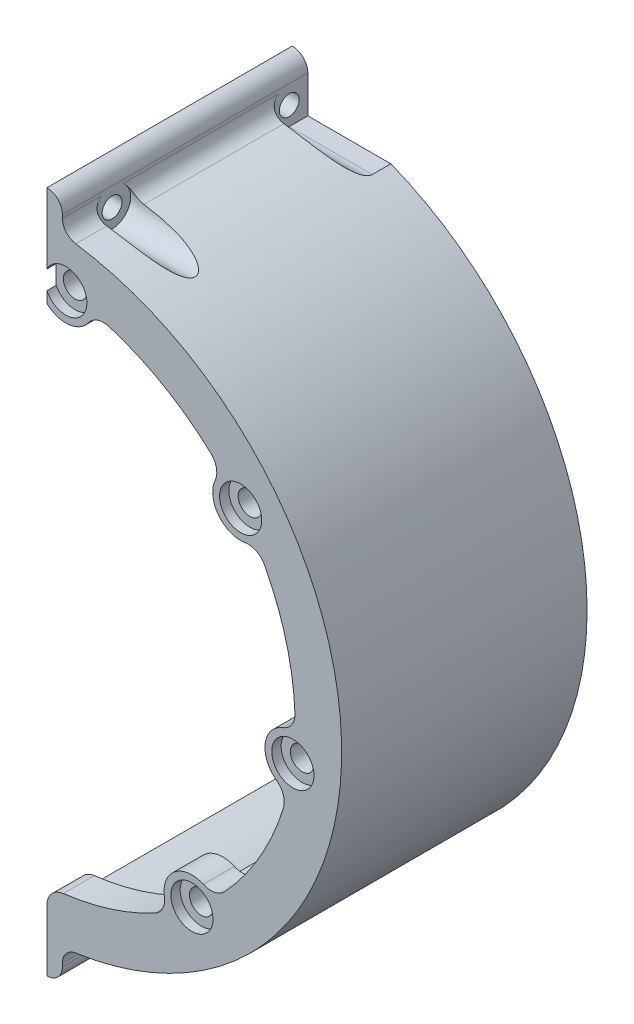
from build123d import *

# Parameters (mm, degrees)
EXTRUDE_1_DEPTH      = 5
EXTRUDE_2_DEPTH      = 34.55
SKETCH_3_W           = 2.5
SKETCH_3_H           = 100
CUT_EXTRUDE_1_DEPTH  = 41
SKETCH_4_R           = 38
CUT_EXTRUDE_2_DEPTH  = 5
EXTRUDE_3_DEPTH      = 39.55
SKETCH_6_R           = 1.9
CUT_EXTRUDE_3_DEPTH  = 10
SKETCH_7_R           = 1.6
CUT_EXTRUDE_4_DEPTH  = 48.5
CUT_EXTRUDE_START    = -2.5
SKETCH_9_R           = 3
CUT_EXTRUDE_7_DEPTH  = 46.0000001
CUT_EXTRUDE_8_DEPTH  = 10
FILLET_1_R           = 3
CUT_EXTRUDE_9_DEPTH  = 34.55
SKETCH_13_R          = 3.4
CUT_EXTRUDE_10_DEPTH = 1.5


with BuildPart() as part:
    # 草图1 → 凸台-拉伸1 (new body)
    with BuildSketch(Plane.XY):
        with BuildLine():
            Line((0, 0), (0, 50))
            ThreePointArc((0, 50), (50, 0), (0, -50))
            Line((0, -50), (0, 0))
        make_face()
    extrude(amount=EXTRUDE_1_DEPTH)

    # 草图2 → 凸台-拉伸2 (add)
    with BuildSketch(Plane(origin=(0, 0, 0), x_dir=(-1, 0, 0), z_dir=(0, 0, -1))):
        with BuildLine():
            Line((0, 46), (0, 50))
            ThreePointArc((0, 50), (-50, 0), (0, -50))
            Line((0, -50), (0, -46))
            ThreePointArc((0, -46), (-46, 0), (0, 46))
        make_face()
    extrude(amount=EXTRUDE_2_DEPTH)

    # 草图3 → 切除-拉伸1 (cut)
    with BuildSketch(Plane.XY.offset(5)):
        with Locations((1.25, 0)):
            Rectangle(SKETCH_3_W, SKETCH_3_H)
    extrude(amount=-CUT_EXTRUDE_1_DEPTH, mode=Mode.SUBTRACT)

    # 草图4 → 切除-拉伸2 (cut)
    with BuildSketch(Plane.XY.offset(5)):
        Circle(SKETCH_4_R)
    extrude(amount=-CUT_EXTRUDE_2_DEPTH, mode=Mode.SUBTRACT)

    # 草图5 → 凸台-拉伸3 (add)
    with BuildSketch(Plane.XY.offset(5)):
        with BuildLine():
            Line((5, -52.5), (5, -51.961524227))
            ThreePointArc((5, -51.961524227), (5.610177635, -50.32489005), (7.142857143, -49.487165931))
            Line((7.142857143, -49.487165931), (2.5, -49.937460889))
            Line((2.5, -49.937460889), (2.5, -55))
            ThreePointArc((2.5, -55), (4.267766953, -54.267766953), (5, -52.5))
        make_face()
        with BuildLine():
            Line((2.5, 55), (2.5, 49.937460889))
            Line((2.5, 49.937460889), (7.142857143, 49.487165931))
            ThreePointArc((7.142857143, 49.487165931), (5.610177635, 50.32489005), (5, 51.961524227))
            Line((5, 51.961524227), (5, 52.5))
            ThreePointArc((5, 52.5), (4.267766953, 54.267766953), (2.5, 55))
        make_face()
    extrude(amount=-EXTRUDE_3_DEPTH)

    # 草图6 → 切除-拉伸3 (cut)
    with BuildSketch(Plane.XY.offset(5)):
        with Locations((33.717516962, 25.872360733)):
            Circle(SKETCH_6_R)
        with Locations((5.547363169, 42.136406608)):
            Circle(SKETCH_6_R)
        with Locations((42.136406608, -5.547363169)):
            Circle(SKETCH_6_R)
        with Locations((25.872360733, -33.717516962)):
            Circle(SKETCH_6_R)
        with Locations((-5.547363169, -42.136406608)):
            Circle(SKETCH_6_R)
        with Locations((-33.717516962, -25.872360733)):
            Circle(SKETCH_6_R)
        with Locations((-42.136406608, 5.547363169)):
            Circle(SKETCH_6_R)
        with Locations((-25.872360733, 33.717516962)):
            Circle(SKETCH_6_R)
    extrude(amount=-CUT_EXTRUDE_3_DEPTH, mode=Mode.SUBTRACT)

    # 草图7 → 切除-拉伸4 (cut, through all)
    with BuildSketch(Plane.ZY.offset(-2.5)):
        with Locations((-3, 49.5)):
            Circle(SKETCH_7_R)
        with Locations((-31.55, 49.5)):
            Circle(SKETCH_7_R)
        with Locations((-31.55, -49.5)):
            Circle(SKETCH_7_R)
        with Locations((-3, -49.5)):
            Circle(SKETCH_7_R)
    extrude(amount=-CUT_EXTRUDE_4_DEPTH, mode=Mode.SUBTRACT)

    # 草图9 → 切除-拉伸7 (cut, through all)
    with BuildSketch(Plane.ZY.offset(-2.5).offset(CUT_EXTRUDE_START)):
        with Locations((-3, 49.5)):
            Circle(SKETCH_9_R)
        with Locations((-3, -49.5)):
            Circle(SKETCH_9_R)
        with BuildLine():
            Line((-31.55, 52.5), (-34.55, 52.5))
            Line((-34.55, 52.5), (-34.55, 46.5))
            Line((-34.55, 46.5), (-31.55, 46.5))
            ThreePointArc((-31.55, 46.5), (-28.55, 49.5), (-31.55, 52.5))
        make_face()
        with BuildLine():
            Line((-31.55, -46.5), (-34.55, -46.5))
            Line((-34.55, -46.5), (-34.55, -52.5))
            Line((-34.55, -52.5), (-31.55, -52.5))
            ThreePointArc((-31.55, -52.5), (-28.55, -49.5), (-31.55, -46.5))
        make_face()
    extrude(amount=-CUT_EXTRUDE_7_DEPTH, mode=Mode.SUBTRACT)

    # 草图11 → 切除-拉伸8 (cut)
    with BuildSketch(Plane(origin=(0, 0, 0), x_dir=(-1, 0, 0), z_dir=(0, 0, -1))):
        with BuildLine():
            ThreePointArc((-30.147426931, 23.132934302), (-19, 32.908965344), (-4.959995304, 37.674904732))
            ThreePointArc((-4.959995304, 37.674904732), (-8.191293479, 38.495028776), (-9.971512435, 41.313665291))
            ThreePointArc((-9.971512435, 41.313665291), (-21.25, 36.806079661), (-30.792927448, 29.292415728))
            ThreePointArc((-30.792927448, 29.292415728), (-29.2420261, 26.34138263), (-30.147426931, 23.132934302))
        make_face()
        with BuildLine():
            ThreePointArc((-37.674904732, -4.959995304), (-36.705181399, 9.835123714), (-30.147426931, 23.132934302))
            ThreePointArc((-30.147426931, 23.132934302), (-33.012215055, 21.427976724), (-36.264096944, 22.162248821))
            ThreePointArc((-36.264096944, 22.162248821), (-41.051847617, 10.999809417), (-42.48675361, -1.061022012))
            ThreePointArc((-42.48675361, -1.061022012), (-39.303405234, -2.051064667), (-37.674904732, -4.959995304))
        make_face()
        with BuildLine():
            ThreePointArc((-23.132934302, -30.147426931), (-32.908965344, -19), (-37.674904732, -4.959995304))
            ThreePointArc((-37.674904732, -4.959995304), (-38.495028776, -8.191293479), (-41.313665291, -9.971512435))
            ThreePointArc((-41.313665291, -9.971512435), (-36.806079661, -21.25), (-29.292415728, -30.792927448))
            ThreePointArc((-29.292415728, -30.792927448), (-26.34138263, -29.2420261), (-23.132934302, -30.147426931))
        make_face()
        with BuildLine():
            ThreePointArc((-2.5, -37.917673979), (-13.392386458, -35.561833262), (-23.132934302, -30.147426931))
            ThreePointArc((-23.132934302, -30.147426931), (-21.427976724, -33.012215055), (-22.162248821, -36.264096944))
            ThreePointArc((-22.162248821, -36.264096944), (-12.710237808, -40.554899271), (-2.5, -42.426406871))
            Line((-2.5, -42.426406871), (-2.5, -37.917673979))
        make_face()
        with BuildLine():
            ThreePointArc((23.132934302, 30.147426931), (9.835123714, 36.705181399), (-4.959995304, 37.674904732))
            ThreePointArc((-4.959995304, 37.674904732), (-2.051064667, 39.303405234), (-1.061022012, 42.48675361))
            ThreePointArc((-1.061022012, 42.48675361), (10.999809417, 41.051847617), (22.162248821, 36.264096944))
            ThreePointArc((22.162248821, 36.264096944), (21.427976724, 33.012215055), (23.132934302, 30.147426931))
        make_face()
    extrude(amount=-CUT_EXTRUDE_8_DEPTH, mode=Mode.SUBTRACT)

    # 圆角1
    fillet_1_edges = [part.edges().sort_by_distance(p)[0] for p in [
        (9.971512435, 41.313665291, 2.5),
        (30.792927448, 29.292415728, 2.5),
        (41.313665291, -9.971512435, 2.5),
        (29.292415728, -30.792927448, 2.5),
        (36.264096944, 22.162248821, 2.5),
        (42.48675361, -1.061022012, 2.5),
        (22.162248821, -36.264096944, 2.5),
        (2.5, -42.426406871, 2.5),
    ]]
    fillet(fillet_1_edges, radius=FILLET_1_R)

    # 草图12 → 切除-拉伸9 (cut)
    with BuildSketch(Plane(origin=(0, 0, -34.55), x_dir=(-1, 0, 0), z_dir=(0, 0, -1))):
        with BuildLine():
            Line((-2.5, 43.5), (0, 0))
            Line((0, 0), (-2.5, -43.5))
            Line((-2.5, -43.5), (-20.291623888, -43.5))
            ThreePointArc((-20.291623888, -43.5), (-48, 0), (-20.291623888, 43.5))
            Line((-20.291623888, 43.5), (-2.5, 43.5))
        make_face()
    extrude(amount=-CUT_EXTRUDE_9_DEPTH, mode=Mode.SUBTRACT)

    # 草图13 → 切除-拉伸10 (cut)
    with BuildSketch(Plane.XY.offset(5)):
        with Locations((5.547363169, 42.136406608)):
            Circle(SKETCH_13_R)
        with Locations((33.717516962, 25.872360733)):
            Circle(SKETCH_13_R)
        with Locations((42.136406608, -5.547363169)):
            Circle(SKETCH_13_R)
        with Locations((25.872360733, -33.717516962)):
            Circle(SKETCH_13_R)
    extrude(amount=-CUT_EXTRUDE_10_DEPTH, mode=Mode.SUBTRACT)


solid = part.part
